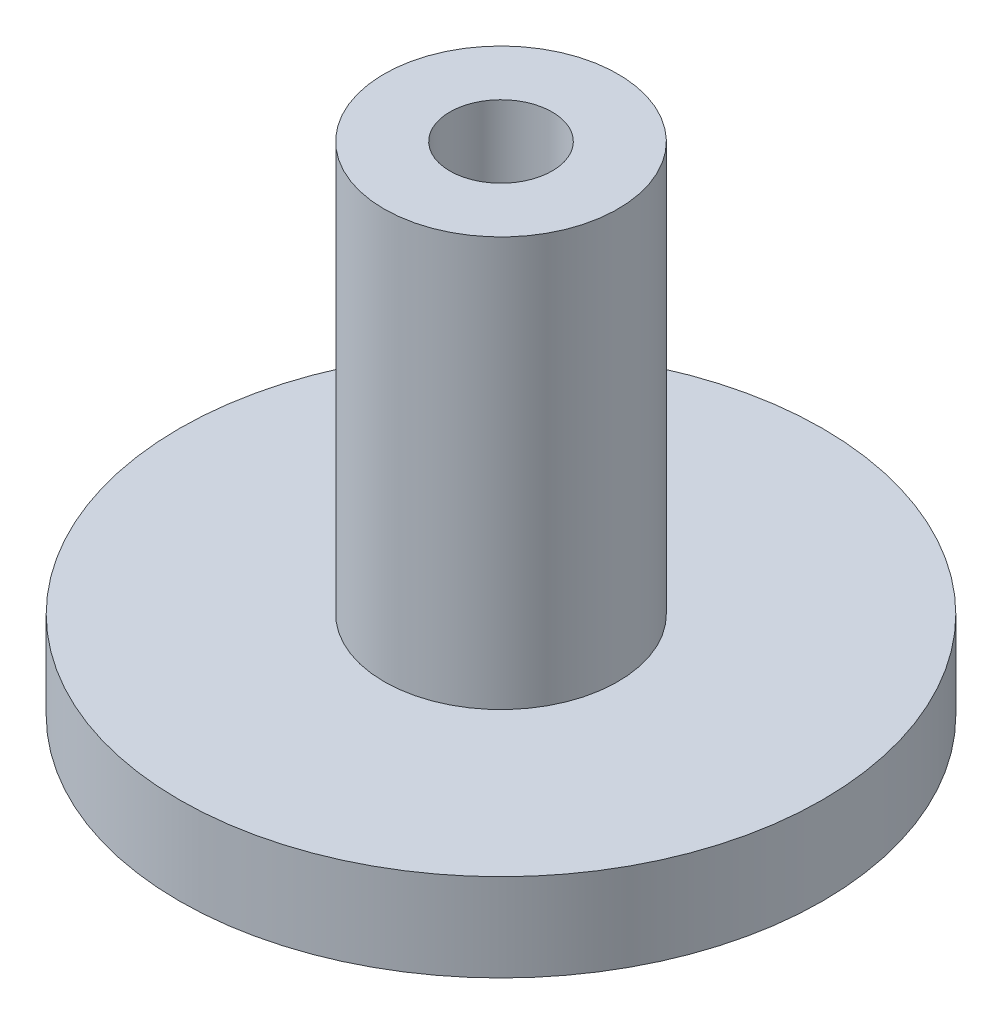
from build123d import *

# Parameters (mm, degrees)
SKETCH1_R           = 11
BOSS_EXTRUDE1_DEPTH = 3
SKETCH2_R           = 4
BOSS_EXTRUDE2_DEPTH = 14
SKETCH3_R           = 1.75
CUT_EXTRUDE1_DEPTH  = 20


with BuildPart() as part:
    # Sketch1 → Boss-Extrude1 (new body)
    with BuildSketch(Plane(origin=(0, 0, 0), x_dir=(1, 0, 0), z_dir=(0, 1, 0))):
        Circle(SKETCH1_R)
    extrude(amount=BOSS_EXTRUDE1_DEPTH)

    # Sketch2 → Boss-Extrude2 (add)
    with BuildSketch(Plane(origin=(0, 3, 0), x_dir=(1, 0, 0), z_dir=(0, 1, 0))):
        Circle(SKETCH2_R)
    extrude(amount=BOSS_EXTRUDE2_DEPTH)

    # Sketch3 → Cut-Extrude1 (cut)
    with BuildSketch(Plane(origin=(0, 17, 0), x_dir=(1, 0, 0), z_dir=(0, 1, 0))):
        Circle(SKETCH3_R)
    extrude(amount=-CUT_EXTRUDE1_DEPTH, mode=Mode.SUBTRACT)


solid = part.part
